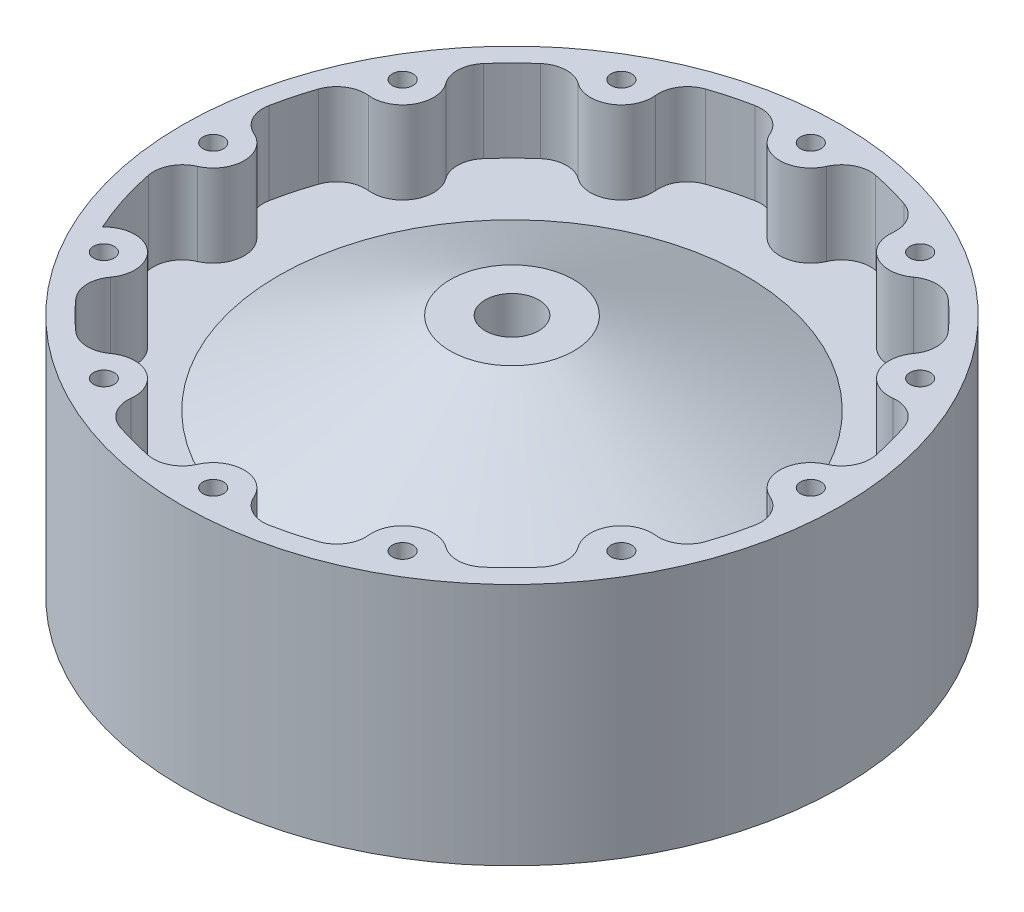
from build123d import *

# Parameters (mm, degrees)
SKETCH15_R            = 9.525
BOSS_EXTRUDE3_DEPTH   = 25.4
SKETCH17_R            = 3.175
CUT_EXTRUDE5_DEPTH    = 25.4
CIRPATTERN5_COUNT     = 12
FILLET2_R             = 8.89
BODY_MOVE_COPY1_ANGLE = 90


with BuildPart() as part:
    # Sketch1 → Revolve1 (revolve)
    with BuildSketch(Plane(origin=(0, 0, 0), x_dir=(1, 0, 0), z_dir=(0, 1, 0))):
        with BuildLine():
            add(Edge.make_bspline(
                [(95.25, 0), (95.25, 56.03262193), (8.255, 60.888782497)],
                knots=[3.141592654, 3.141592654, 3.141592654, 4.625613452, 4.625613452, 4.625613452], degree=2, weights=[1, 0.73711148, 1]))
            Line((95.25, 0), (101.6, 0))
            Line((101.6, 0), (101.6, 61.11875))
            Line((101.6, 61.11875), (101.6, 75.08875))
            Line((101.6, 75.08875), (95.25, 75.08875))
            Line((95.25, 75.08875), (95.25, 49.68875))
            Line((95.25, 49.68875), (71.966666667, 49.68875))
            Line((71.966666667, 49.68875), (19.05, 75.08875))
            Line((19.05, 75.08875), (8.255, 75.08875))
            Line((8.255, 75.08875), (8.255, 60.888782497))
        make_face()
    revolve(axis=Axis((0, 0, 0), (0, 0, -1)))

    # Sketch15 → Boss-Extrude3 (add)
    with BuildSketch(Plane(origin=(0, 0, -75.08875), x_dir=(-1, 0, 0), z_dir=(0, 0, -1))):
        with Locations((0, -92.075)):
            Circle(SKETCH15_R)
    boss_extrude3 = extrude(amount=-BOSS_EXTRUDE3_DEPTH)

    # Sketch17 → Cut-Extrude5 (cut)
    with BuildSketch(Plane(origin=(0, 0, -75.08875), x_dir=(-1, 0, 0), z_dir=(0, 0, -1))):
        with Locations((0, -92.075)):
            Circle(SKETCH17_R)
    cut_extrude5 = extrude(amount=-CUT_EXTRUDE5_DEPTH, mode=Mode.SUBTRACT)

    # CirPattern5: Boss-Extrude3, Cut-Extrude5 ×12 about axis
    cirpattern5_axis = Axis((0, 0, 0), (0, 0, 1))
    for i in range(1, CIRPATTERN5_COUNT):
        add(boss_extrude3.rotate(cirpattern5_axis, i * 360 / CIRPATTERN5_COUNT))
        add(cut_extrude5.rotate(cirpattern5_axis, i * 360 / CIRPATTERN5_COUNT), mode=Mode.SUBTRACT)

    # Fillet2
    fillet2_edges = [part.edges().sort_by_distance(p)[0] for p in [
        (-55.307019159, 77.54802468, -62.38875),
        (-39.505049806, 86.671295939, -62.38875),
        (-77.54802468, 55.307019159, -62.38875),
        (-94.812068966, -9.12327126, -62.38875),
        (-94.812068966, 9.12327126, -62.38875),
        (-77.54802468, -55.307019159, -62.38875),
        (-86.671295939, -39.505049806, -62.38875),
        (-39.505049806, -86.671295939, -62.38875),
        (-55.307019159, -77.54802468, -62.38875),
        (9.12327126, -94.812068966, -62.38875),
        (-9.12327126, -94.812068966, -62.38875),
        (55.307019159, -77.54802468, -62.38875),
        (39.505049806, -86.671295939, -62.38875),
        (86.671295939, -39.505049806, -62.38875),
        (77.54802468, -55.307019159, -62.38875),
        (94.812068966, 9.12327126, -62.38875),
        (94.812068966, -9.12327126, -62.38875),
        (77.54802468, 55.307019159, -62.38875),
        (86.671295939, 39.505049806, -62.38875),
        (39.505049806, 86.671295939, -62.38875),
        (55.307019159, 77.54802468, -62.38875),
        (-9.12327126, 94.812068966, -62.38875),
        (9.12327126, 94.812068966, -62.38875),
    ]]
    fillet(fillet2_edges, radius=FILLET2_R)


with BuildPart() as part_1:
    # Body-Move/Copy1: moved
    add(part.part.rotate(Axis((0, 0, -37.544375), (1, 0, 0)), BODY_MOVE_COPY1_ANGLE))


solid = part_1.part
